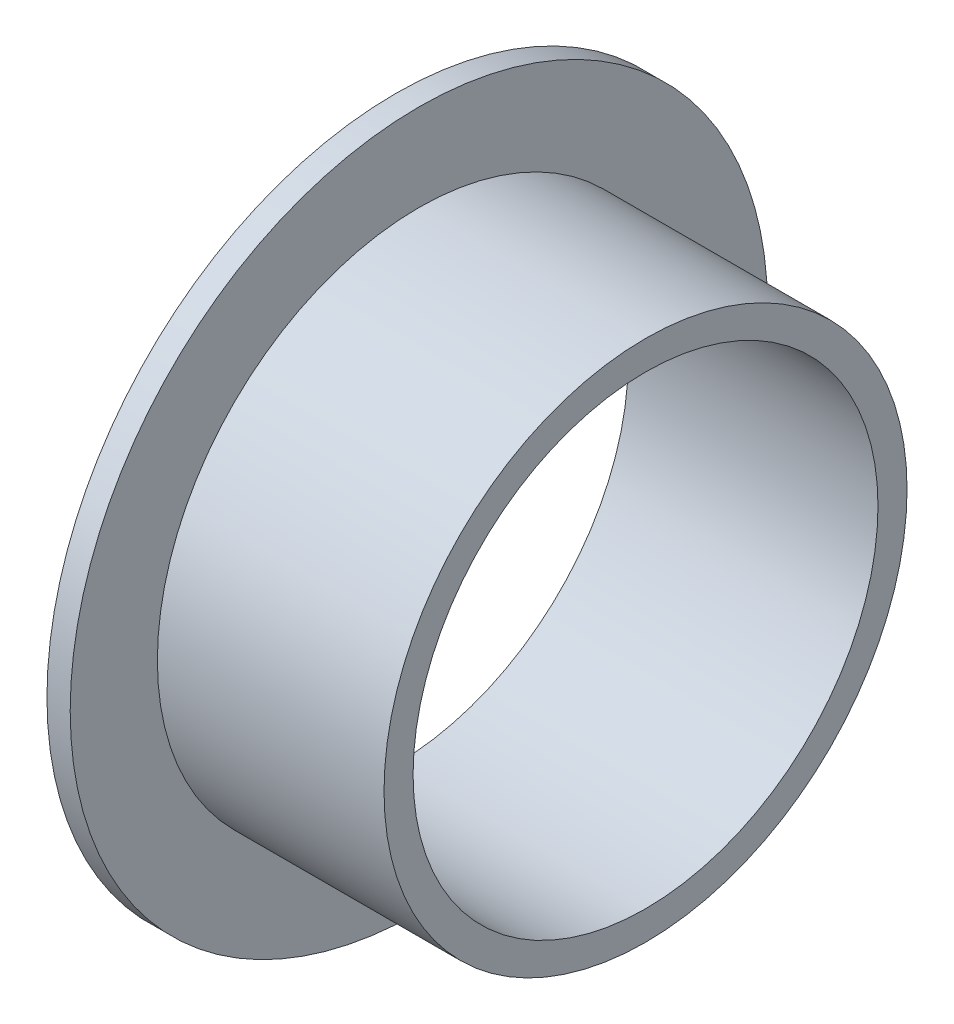
from build123d import *


with BuildPart() as part:
    # Esquisse1 → Révolution1 (revolve)
    with BuildSketch(Plane.XY):
        Polygon((0, 8), (8.6, 8), (8.6, 9), (0.8, 9), (0.8, 12), (0, 12), align=None)
    revolve(axis=Axis((0, 0, 0), (1, 0, 0)))


solid = part.part
